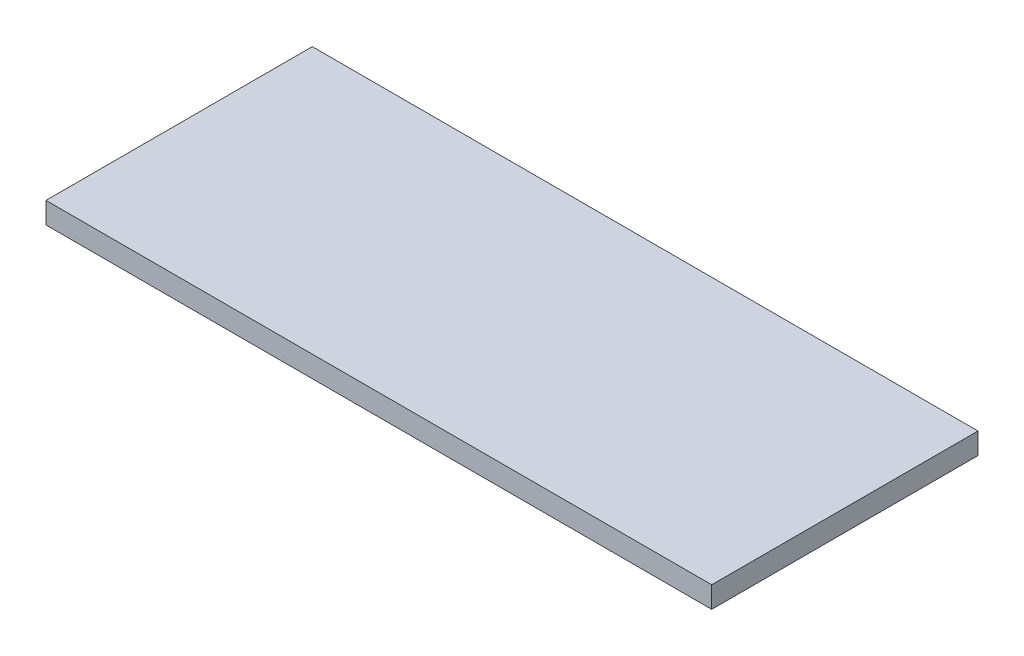
from build123d import *

# Parameters (mm, degrees)
SKETCH1_W           = 50
SKETCH1_H           = 20
BOSS_EXTRUDE1_DEPTH = 1.6


with BuildPart() as part:
    # Sketch1 → Boss-Extrude1 (new body)
    with BuildSketch(Plane(origin=(0, 0, 0), x_dir=(1, 0, 0), z_dir=(0, 1, 0))):
        with Locations((25, 10)):
            Rectangle(SKETCH1_W, SKETCH1_H)
    extrude(amount=BOSS_EXTRUDE1_DEPTH)


solid = part.part
